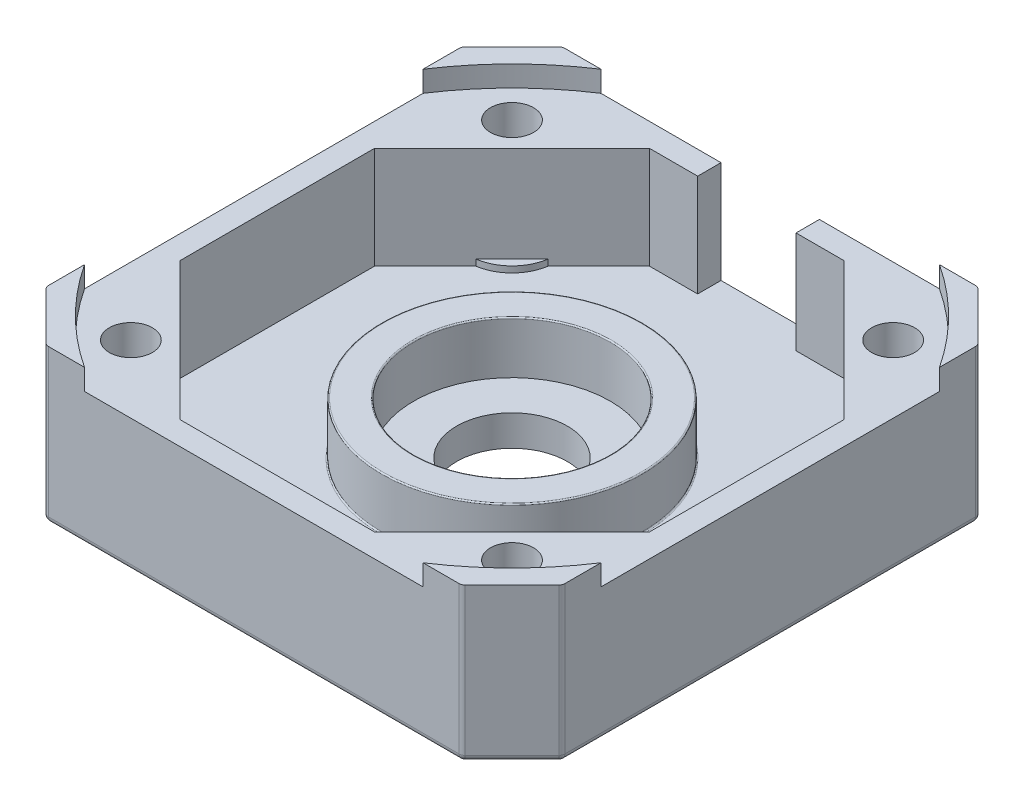
from build123d import *

# Parameters (mm, degrees)
SKETCH_1_W          = 42
SKETCH_1_H          = 42
EXTRUDE_1_DEPTH     = 12.5
CUT_EXTRUDE_1_DEPTH = 12.5
CUT_EXTRUDE_2_DEPTH = 10
SKETCH_4_R          = 25.11
CUT_EXTRUDE_3_DEPTH = 1.7
SKETCH_5_R          = 10.6
SKETCH_5_R_2        = 8
EXTRUDE_2_DEPTH     = 4.25
SKETCH_6_R          = 4.5
CUT_EXTRUDE_4_DEPTH = 2.5
SKETCH_8_R          = 1.75
CUT_EXTRUDE_5_DEPTH = 10.8
SKETCH_9_R          = 3
CUT_EXTRUDE_6_DEPTH = 2.62
EXTRUDE_3_DEPTH     = 0.5
CUT_EXTRUDE_7_DEPTH = 0.12
SKETCH_13_W         = 8
SKETCH_13_H         = 8.3
CUT_EXTRUDE_8_DEPTH = 1.9
FILLET_1_R          = 0.1
FILLET_2_R          = 0.5


with BuildPart() as part:
    # Эскиз1 → Бобышка-Вытянуть1 (new body)
    with BuildSketch(Plane(origin=(0, 0, 0), x_dir=(1, 0, 0), z_dir=(0, 1, 0))):
        Rectangle(SKETCH_1_W, SKETCH_1_H)
    extrude(amount=EXTRUDE_1_DEPTH)

    # Эскиз2 → Вырез-Вытянуть1 (cut)
    with BuildSketch(Plane(origin=(0, 12.5, 0), x_dir=(1, 0, 0), z_dir=(0, 1, 0))):
        Polygon((-21, 21), (-21, 16.900923472), (-16.900923472, 21), align=None)
        Polygon((21, 21), (16.900923472, 21), (21, 16.900923472), align=None)
        Polygon((-21, -21), (-21, -16.900923472), (-16.900923472, -21), align=None)
        Polygon((21, -21), (21, -16.900923472), (16.900923472, -21), align=None)
    extrude(amount=-CUT_EXTRUDE_1_DEPTH, mode=Mode.SUBTRACT)

    # Эскиз3 → Вырез-Вытянуть2 (cut)
    with BuildSketch(Plane(origin=(0, 12.5, 0), x_dir=(1, 0, 0), z_dir=(0, 1, 0))):
        Polygon((-7.911479041, 19.1), (7.911479041, 19.1), (19.1, 7.911479041), (19.1, -7.911479041), (7.911479041, -19.1), (-7.911479041, -19.1), (-19.1, -7.911479041), (-19.1, 7.911479041), align=None)
    extrude(amount=-CUT_EXTRUDE_2_DEPTH, mode=Mode.SUBTRACT)

    # Эскиз4 → Вырез-Вытянуть3 (cut)
    with BuildSketch(Plane(origin=(0, 12.5, 0), x_dir=(1, 0, 0), z_dir=(0, 1, 0))):
        Circle(SKETCH_4_R)
    extrude(amount=-CUT_EXTRUDE_3_DEPTH, mode=Mode.SUBTRACT)

    # Эскиз5 → Бобышка-Вытянуть2 (add)
    with BuildSketch(Plane(origin=(0, 2.5, 0), x_dir=(1, 0, 0), z_dir=(0, 1, 0))):
        Circle(SKETCH_5_R)
        Circle(SKETCH_5_R_2, mode=Mode.SUBTRACT)
    extrude(amount=EXTRUDE_2_DEPTH)

    # Эскиз6 → Вырез-Вытянуть4 (cut)
    with BuildSketch(Plane(origin=(0, 2.5, 0), x_dir=(1, 0, 0), z_dir=(0, 1, 0))):
        Circle(SKETCH_6_R)
    extrude(amount=-CUT_EXTRUDE_4_DEPTH, mode=Mode.SUBTRACT)

    # Эскиз8 → Вырез-Вытянуть5 (cut)
    with BuildSketch(Plane(origin=(0, 10.8, 0), x_dir=(1, 0, 0), z_dir=(0, 1, 0))):
        with Locations((-15.5, 15.5)):
            Circle(SKETCH_8_R)
        with Locations((15.5, 15.5)):
            Circle(SKETCH_8_R)
        with Locations((-15.5, -15.5)):
            Circle(SKETCH_8_R)
        with Locations((15.5, -15.5)):
            Circle(SKETCH_8_R)
    extrude(amount=-CUT_EXTRUDE_5_DEPTH, mode=Mode.SUBTRACT)

    # Эскиз9 → Вырез-Вытянуть6 (cut)
    with BuildSketch(Plane.XZ):
        with Locations((-15.5, 15.5)):
            Circle(SKETCH_9_R)
        with Locations((15.5, 15.5)):
            Circle(SKETCH_9_R)
        with Locations((15.5, -15.5)):
            Circle(SKETCH_9_R)
        with Locations((-15.5, -15.5)):
            Circle(SKETCH_9_R)
    extrude(amount=-CUT_EXTRUDE_6_DEPTH, mode=Mode.SUBTRACT)

    # Эскиз11 → Бобышка-Вытянуть3 (add)
    with BuildSketch(Plane(origin=(0, 2.5, 0), x_dir=(1, 0, 0), z_dir=(0, 1, 0))):
        with BuildLine():
            Line((14.971319659, -12.040159383), (12.040159383, -14.971319659))
            ThreePointArc((12.040159383, -14.971319659), (13.025126266, -13.025126266), (14.971319659, -12.040159383))
        make_face()
        with BuildLine():
            Line((-12.040159383, -14.971319659), (-14.971319659, -12.040159383))
            ThreePointArc((-14.971319659, -12.040159383), (-13.025126266, -13.025126266), (-12.040159383, -14.971319659))
        make_face()
        with BuildLine():
            Line((-14.971319659, 12.040159383), (-12.040159383, 14.971319659))
            ThreePointArc((-12.040159383, 14.971319659), (-13.025126266, 13.025126266), (-14.971319659, 12.040159383))
        make_face()
        with BuildLine():
            Line((12.040159383, 14.971319659), (14.971319659, 12.040159383))
            ThreePointArc((14.971319659, 12.040159383), (13.025126266, 13.025126266), (12.040159383, 14.971319659))
        make_face()
    extrude(amount=EXTRUDE_3_DEPTH)

    # Эскиз12 → Вырез-Вытянуть7 (cut)
    with BuildSketch(Plane.XZ.offset(-2.5)):
        with BuildLine():
            Line((-14.228875151, -12.78260389), (-12.78260389, -14.228875151))
            ThreePointArc((-12.78260389, -14.228875151), (-13.378679656, -13.378679656), (-14.228875151, -12.78260389))
        make_face()
        with BuildLine():
            Line((-12.78260389, 14.228875151), (-14.228875151, 12.78260389))
            ThreePointArc((-14.228875151, 12.78260389), (-13.378679656, 13.378679656), (-12.78260389, 14.228875151))
        make_face()
        with BuildLine():
            Line((14.228875151, 12.78260389), (12.78260389, 14.228875151))
            ThreePointArc((12.78260389, 14.228875151), (13.378679656, 13.378679656), (14.228875151, 12.78260389))
        make_face()
        with BuildLine():
            Line((12.78260389, -14.228875151), (14.228875151, -12.78260389))
            ThreePointArc((14.228875151, -12.78260389), (13.378679656, -13.378679656), (12.78260389, -14.228875151))
        make_face()
    extrude(amount=-CUT_EXTRUDE_7_DEPTH, mode=Mode.SUBTRACT)

    # Эскиз13 → Вырез-Вытянуть8 (cut)
    with BuildSketch(Plane(origin=(0, 0, -21), x_dir=(-1, 0, 0), z_dir=(0, 0, -1))):
        with Locations((0, 6.65)):
            Rectangle(SKETCH_13_W, SKETCH_13_H)
    extrude(amount=-CUT_EXTRUDE_8_DEPTH, mode=Mode.SUBTRACT)

    # Скругление1
    fillet_1_edges = [part.edges().sort_by_distance(p)[0] for p in [
        (-10.6, 2.5, 0),
        (-10.6, 6.75, 0),
        (-8, 6.75, 0),
        (-18.5, 0, 15.5),
        (12.5, 0, 15.5),
        (12.5, 0, -15.5),
        (-18.5, 0, -15.5),
    ]]
    fillet(fillet_1_edges, radius=FILLET_1_R)

    # Скругление2
    fillet_2_edges = [part.edges().sort_by_distance(p)[0] for p in [
        (-21, 0, 0),
        (-16.900923472, 6.25, -21),
        (-21, 6.25, -16.900923472),
        (-18.950461736, 0, -18.950461736),
        (0, 0, -21),
        (21, 6.25, -16.900923472),
        (16.900923472, 6.25, -21),
        (18.950461736, 0, -18.950461736),
        (0, 0, 21),
        (-16.900923472, 6.25, 21),
        (-21, 6.25, 16.900923472),
        (-18.950461736, 0, 18.950461736),
        (21, 0, 0),
        (16.900923472, 6.25, 21),
        (21, 6.25, 16.900923472),
        (18.950461736, 0, 18.950461736),
    ]]
    fillet(fillet_2_edges, radius=FILLET_2_R)


solid = part.part
